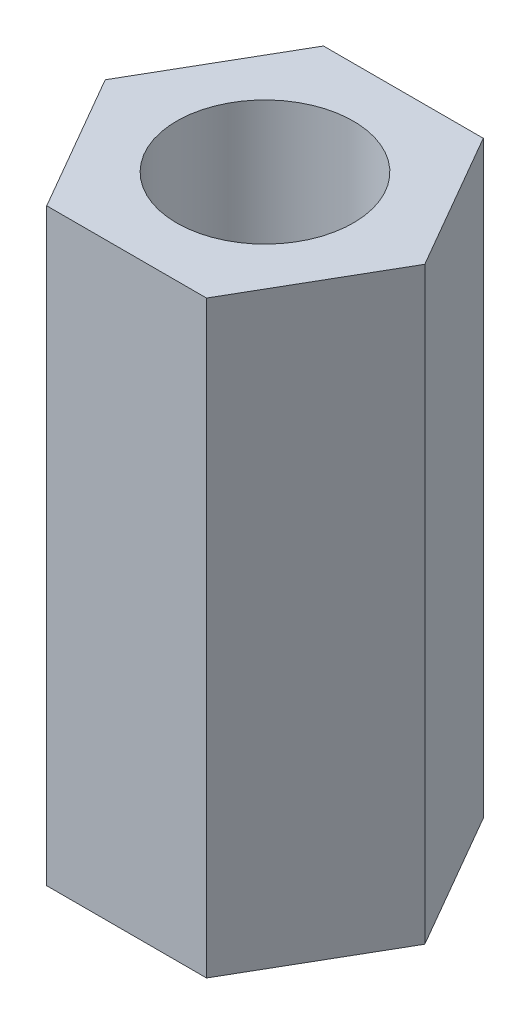
from build123d import *

# Parameters (mm, degrees)
EXTRUDE_1_DEPTH     = 10
SKETCH_2_R          = 1.5
CUT_EXTRUDE_1_DEPTH = 11


with BuildPart() as part:
    # 草图1 → 凸台-拉伸1 (new body)
    with BuildSketch(Plane(origin=(0, 0, 0), x_dir=(1, 0, 0), z_dir=(0, 1, 0))):
        Polygon((2.713546265, 0), (1.356773133, 2.35), (-1.356773133, 2.35), (-2.713546265, 0), (-1.356773133, -2.35), (1.356773133, -2.35), align=None)
    extrude(amount=EXTRUDE_1_DEPTH)

    # 草图2 → 切除-拉伸1 (cut, through all)
    with BuildSketch(Plane(origin=(0, 10, 0), x_dir=(1, 0, 0), z_dir=(0, 1, 0))):
        Circle(SKETCH_2_R)
    extrude(amount=-CUT_EXTRUDE_1_DEPTH, mode=Mode.SUBTRACT)


solid = part.part
